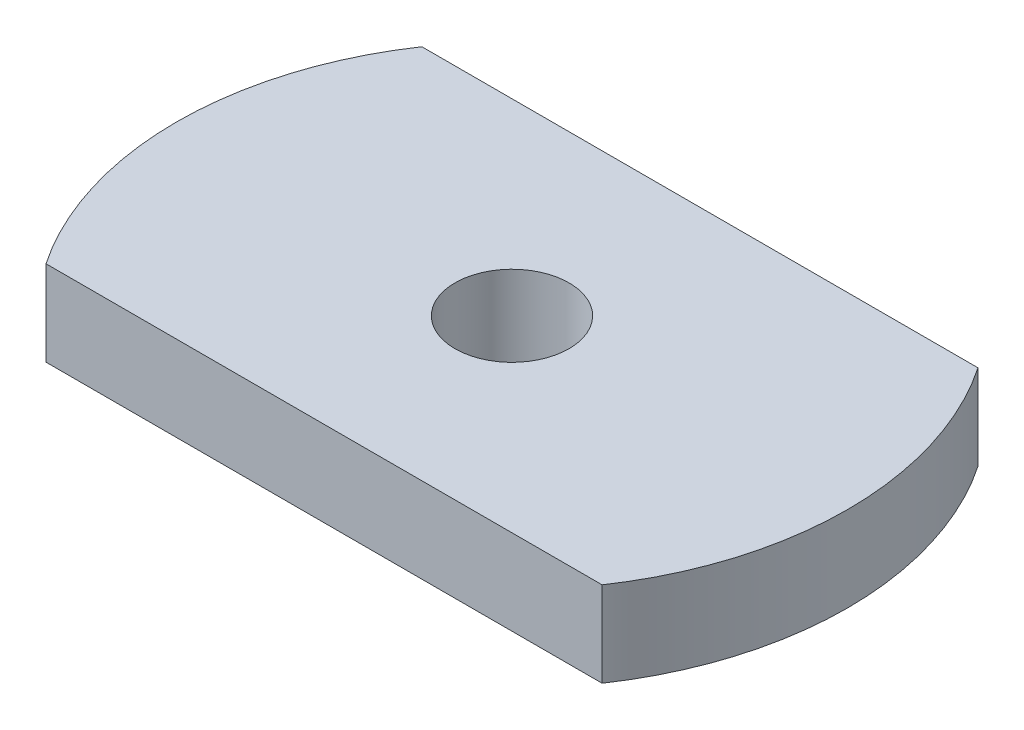
from build123d import *

# Parameters (mm, degrees)
ESBO_O1_R                = 4.25
RESSALTO_EXTRUS_O1_DEPTH = 6.35


with BuildPart() as part:
    # Esboço1 → Ressalto-extrusão1 (new body)
    with BuildSketch(Plane(origin=(0, 0, 0), x_dir=(1, 0, 0), z_dir=(0, 1, 0))):
        with BuildLine():
            Line((-20.712315177, 14), (20.712315177, 14))
            ThreePointArc((20.712315177, 14), (25, 0), (20.712315177, -14))
            Line((20.712315177, -14), (-20.712315177, -14))
            ThreePointArc((-20.712315177, -14), (-25, 0), (-20.712315177, 14))
        make_face()
        Circle(ESBO_O1_R, mode=Mode.SUBTRACT)
    extrude(amount=RESSALTO_EXTRUS_O1_DEPTH)


solid = part.part
